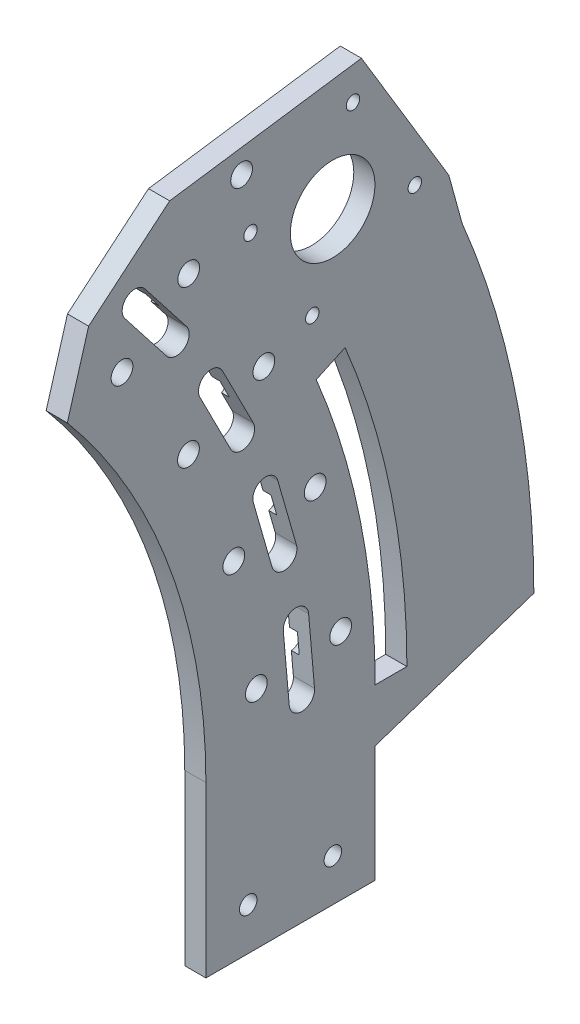
from build123d import *

# Parameters (mm, degrees)
SKETCH1_R           = 2.6289
SKETCH1_R_2         = 2.0193
SKETCH1_R_3         = 12.7
BOSS_EXTRUDE1_DEPTH = 6.35
SKETCH8_R           = 3.2639
CUT_EXTRUDE1_DEPTH  = 7.35
CUT_EXTRUDE2_START  = -2.38125
SKETCH9_R           = 3.175
CUT_EXTRUDE2_DEPTH  = 12.41425
CIRPATTERN1_COUNT   = 4
CIRPATTERN1_ANGLE   = 33
SKETCH10_R          = 3.2639
CUT_EXTRUDE3_DEPTH  = 7.35


with BuildPart() as part:
    # Sketch1 → Boss-Extrude1 (new body)
    with BuildSketch(Plane(origin=(0, 0, 0), x_dir=(0, 0, -1), z_dir=(1, 0, 0))):
        with BuildLine():
            ThreePointArc((136.202701987, 114.287637002), (167.077347976, 60.811181483), (177.8, 0))
            Line((177.8, 0), (177.8, -50.8))
            Line((177.8, -50.8), (228.6, -50.8))
            Line((228.6, -50.8), (228.6, -15.875))
            Line((228.6, -15.875), (276.225, 0))
            ThreePointArc((276.225, 0), (270.787208867, 54.539326538), (254.687933194, 106.93132053))
            Line((254.687933194, 106.93132053), (250.70144255, 121.427783901))
            Line((250.70144255, 121.427783901), (237.590987118, 143.182690436))
            Line((237.590987118, 143.182690436), (224.480531685, 164.937596971))
            Line((224.480531685, 164.937596971), (197.194423369, 161.00537172))
            Line((197.194423369, 161.00537172), (166.921891726, 156.642770358))
            Line((166.921891726, 156.642770358), (142.599980657, 136.23426375))
            Line((142.599980657, 136.23426375), (136.202701987, 114.287637002))
        make_face()
        with Locations((190.5, -38.1)):
            Circle(SKETCH1_R, mode=Mode.SUBTRACT)
        with Locations((215.9, -38.1)):
            Circle(SKETCH1_R, mode=Mode.SUBTRACT)
        with BuildLine():
            Line((210.919197755, 88.15357065), (219.558563098, 92.182172871))
            ThreePointArc((219.558563098, 92.182172871), (233.437249023, 47.016660809), (238.125, 0))
            Line((238.125, 0), (228.6, 0))
            ThreePointArc((228.6, 0), (224.136218188, 44.954595945), (210.919197755, 88.15357065))
        make_face(mode=Mode.SUBTRACT)
        with Locations((191.182546707, 136.184784997)):
            Circle(SKETCH1_R_2, mode=Mode.SUBTRACT)
        with Locations((209.723530589, 105.418701127)):
            Circle(SKETCH1_R_2, mode=Mode.SUBTRACT)
        with Locations((215.836080583, 130.072235003)):
            Circle(SKETCH1_R_3, mode=Mode.SUBTRACT)
        with Locations((240.489614459, 123.959685009)):
            Circle(SKETCH1_R_2, mode=Mode.SUBTRACT)
        with Locations((221.948630577, 154.725768879)):
            Circle(SKETCH1_R_2, mode=Mode.SUBTRACT)
    extrude(amount=BOSS_EXTRUDE1_DEPTH)

    # Sketch8 → Cut-Extrude1 (cut, through all)
    with BuildSketch(Plane.ZY):
        with Locations((-218.241353484, 19.093644342)):
            Circle(SKETCH8_R)
        with Locations((-192.938008153, 16.879888477)):
            Circle(SKETCH8_R)
        with Locations((-210.588406038, 60.385253726)):
            Circle(SKETCH8_R)
        with Locations((-186.172358961, 53.384064888)):
            Circle(SKETCH8_R)
        with Locations((-195.197254287, 99.45796873)):
            Circle(SKETCH8_R)
        with Locations((-172.565688572, 87.926610037)):
            Circle(SKETCH8_R)
        with Locations((-172.633455846, 134.876037707)):
            Circle(SKETCH8_R)
        with Locations((-152.617982705, 119.238236234)):
            Circle(SKETCH8_R)
        with BuildLine():
            Line((-201.035193399, 27.787109942), (-202.806198092, 7.544433676))
            ThreePointArc((-202.806198092, 7.544433676), (-206.933763272, 4.080995257), (-210.397201691, 8.208560436))
            Line((-210.397201691, 8.208560436), (-208.626196999, 28.451236701))
            ThreePointArc((-208.626196999, 28.451236701), (-204.498631819, 31.914675121), (-201.035193399, 27.787109942))
        make_face()
        with BuildLine():
            Line((-192.039580138, 65.635905756), (-197.640531208, 46.103068095))
            ThreePointArc((-197.640531208, 46.103068095), (-202.353116595, 43.490839359), (-204.965345331, 48.203424746))
            Line((-204.965345331, 48.203424746), (-199.364394261, 67.736262407))
            ThreePointArc((-199.364394261, 67.736262407), (-194.651808874, 70.348491143), (-192.039580138, 65.635905756))
        make_face()
        with BuildLine():
            Line((-182.776820638, 104.532276267), (-192.001907592, 86.427023695))
            ThreePointArc((-192.001907592, 86.427023695), (-190.336876539, 81.302585034), (-185.212437878, 82.967616087))
            Line((-185.212437878, 82.967616087), (-175.987350923, 101.072868659))
            ThreePointArc((-175.987350923, 101.072868659), (-177.652381977, 106.19730732), (-182.776820638, 104.532276267))
        make_face()
        with BuildLine():
            Line((-159.472997023, 137.487185455), (-171.983238202, 121.474806942))
            ThreePointArc((-171.983238202, 121.474806942), (-171.326587452, 116.12681575), (-165.978596259, 116.7834665))
            Line((-165.978596259, 116.7834665), (-153.468355081, 132.795845013))
            ThreePointArc((-153.468355081, 132.795845013), (-154.125005831, 138.143836206), (-159.472997023, 137.487185455))
        make_face()
    extrude(amount=-CUT_EXTRUDE1_DEPTH, mode=Mode.SUBTRACT)

    # Sketch9 → Cut-Extrude2 (cut)
    with BuildSketch(Plane(origin=(0, 18.329898569, -209.511699345), x_dir=(0, -0.087155743, 0.996194698), z_dir=(-1, 0, 0)).offset(CUT_EXTRUDE2_START)):
        Circle(SKETCH9_R)
        with Locations((7.62, 0)):
            Circle(SKETCH9_R)
    cut_extrude2 = extrude(amount=CUT_EXTRUDE2_DEPTH, mode=Mode.SUBTRACT)

    # CirPattern1: Cut-Extrude2 ×4 about axis
    cirpattern1_axis = Axis((0, 0, 0), (1, 0, 0))
    for i in range(1, CIRPATTERN1_COUNT):
        add(cut_extrude2.rotate(cirpattern1_axis, i * CIRPATTERN1_ANGLE / (CIRPATTERN1_COUNT - 1)), mode=Mode.SUBTRACT)

    # Sketch10 → Cut-Extrude3 (cut, through all)
    with BuildSketch(Plane.ZY):
        with Locations((-188.512295871, 152.654247257)):
            Circle(SKETCH10_R)
    extrude(amount=-CUT_EXTRUDE3_DEPTH, mode=Mode.SUBTRACT)


solid = part.part
